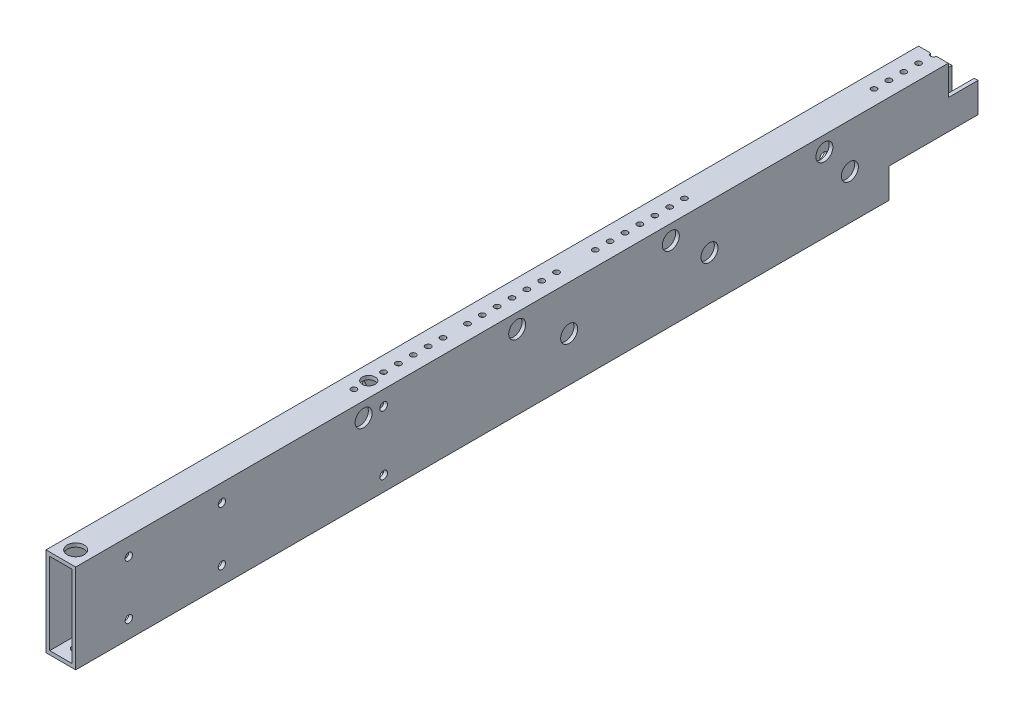
from build123d import *

# Parameters (mm, degrees)
SKETCH1_W                                           = 25.4
SKETCH1_H                                           = 76.2
BOSS_EXTRUDE1_DEPTH                                 = 385.699
SHELL1_T                                            = -3.175
SKETCH2_W                                           = 76.2
SKETCH2_H                                           = 25.4
CUT_EXTRUDE1_DEPTH                                  = 26.4
SKETCH3_W                                           = 25.4
SKETCH3_H                                           = 25.4
CUT_EXTRUDE2_DEPTH                                  = 26.4
SKETCH4_R                                           = 2.38125
CUT_EXTRUDE3_DEPTH                                  = 77.2
CUT_EXTRUDE4_REACH                                  = 78.2
SKETCH5_R                                           = 2.38125
CUT_EXTRUDE5_REACH                                  = 78.2
SKETCH6_R                                           = 2.38125
CBORE_FOR_M6_HEX_HEAD_BOLT1_D                       = 6.3
CBORE_FOR_M6_HEX_HEAD_BOLT1_CBORE_D                 = 14.547
CBORE_FOR_M6_HEX_HEAD_BOLT1_CBORE_DEPTH             = 4
CBORE_FOR_M6_HEX_HEAD_CAP_SCREW1_D                  = 6.6
CBORE_FOR_M6_HEX_HEAD_CAP_SCREW1_CBORE_D            = 14.55
CBORE_FOR_M6_HEX_HEAD_CAP_SCREW1_CBORE_DEPTH        = 4.15
CBORE_FOR_M6_HEX_HEAD_CAP_SCREW2_D                  = 6.6
CBORE_FOR_M6_HEX_HEAD_CAP_SCREW2_CBORE_D            = 14.55
CBORE_FOR_M6_HEX_HEAD_CAP_SCREW2_CBORE_DEPTH        = 4.15
CBORE_FOR_M6_HEX_HEAD_CAP_SCREW3_D                  = 6.6
CBORE_FOR_M6_HEX_HEAD_CAP_SCREW3_CBORE_D            = 14.55
CBORE_FOR_M6_HEX_HEAD_CAP_SCREW3_CBORE_DEPTH        = 4.15
CBORE_FOR_M6_HEX_HEAD_BOLT2_D                       = 6.3
CBORE_FOR_M6_HEX_HEAD_BOLT2_CBORE_D                 = 14.547
CBORE_FOR_M6_HEX_HEAD_BOLT2_CBORE_DEPTH             = 4
CBORE_FOR_M6_HEX_SOCKET_HEAD_CAP_SCREW1_D           = 6.4
CBORE_FOR_M6_HEX_SOCKET_HEAD_CAP_SCREW1_CBORE_D     = 11
CBORE_FOR_M6_HEX_SOCKET_HEAD_CAP_SCREW1_CBORE_DEPTH = 7


with BuildPart() as part:
    # Sketch1 → Boss-Extrude1 (new body, symmetric)
    with BuildSketch(Plane.XY):
        Rectangle(SKETCH1_W, SKETCH1_H)
    extrude(amount=BOSS_EXTRUDE1_DEPTH, both=True)

    # Shell1
    shell1_openings = [part.faces().sort_by_distance(p)[0] for p in [
        (0, 0, 385.699),
        (0, 0, -385.699),
    ]]
    offset(amount=SHELL1_T, openings=shell1_openings, kind=Kind.INTERSECTION)

    # Sketch2 → Cut-Extrude1 (cut, through all)
    with BuildSketch(Plane(origin=(12.7, 0, 0), x_dir=(0, 0, -1), z_dir=(1, 0, 0))):
        with Locations((347.599, -25.4)):
            Rectangle(SKETCH2_W, SKETCH2_H)
    extrude(amount=-CUT_EXTRUDE1_DEPTH, mode=Mode.SUBTRACT)

    # Sketch3 → Cut-Extrude2 (cut, through all)
    with BuildSketch(Plane(origin=(12.7, 0, 0), x_dir=(0, 0, -1), z_dir=(1, 0, 0))):
        with Locations((372.999, 25.4)):
            Rectangle(SKETCH3_W, SKETCH3_H)
    extrude(amount=-CUT_EXTRUDE2_DEPTH, mode=Mode.SUBTRACT)

    # Sketch4 → Cut-Extrude3 (cut, through all)
    with BuildSketch(Plane(origin=(0, 38.1, 0), x_dir=(1, 0, 0), z_dir=(0, 1, 0))):
        with Locations((0, 147.394483214)):
            Circle(SKETCH4_R)
        with Locations((0, 134.694483214)):
            Circle(SKETCH4_R)
        with Locations((0, 121.994483214)):
            Circle(SKETCH4_R)
        with Locations((0, 109.294483214)):
            Circle(SKETCH4_R)
        with Locations((0, 96.594483214)):
            Circle(SKETCH4_R)
        with Locations((0, 83.894483214)):
            Circle(SKETCH4_R)
        with Locations((0, 71.194483214)):
            Circle(SKETCH4_R)
        with Locations((0, 38.09873)):
            Circle(SKETCH4_R)
        with Locations((0, 25.39873)):
            Circle(SKETCH4_R)
        with Locations((0, 12.69873)):
            Circle(SKETCH4_R)
        with Locations((0, -0.00127)):
            Circle(SKETCH4_R)
        with Locations((0, -12.70127)):
            Circle(SKETCH4_R)
        with Locations((0, -25.40127)):
            Circle(SKETCH4_R)
        with Locations((0, -38.10127)):
            Circle(SKETCH4_R)
        with Locations((0, -58.99324371)):
            Circle(SKETCH4_R)
        with Locations((0, -71.69324371)):
            Circle(SKETCH4_R)
        with Locations((0, -84.39324371)):
            Circle(SKETCH4_R)
        with Locations((0, -97.09324371)):
            Circle(SKETCH4_R)
        with Locations((0, -109.79324371)):
            Circle(SKETCH4_R)
        with Locations((0, -122.49324371)):
            Circle(SKETCH4_R)
        with Locations((0, -135.19324371)):
            Circle(SKETCH4_R)
    extrude(amount=-CUT_EXTRUDE3_DEPTH, mode=Mode.SUBTRACT)

    # Sketch5 → Cut-Extrude4 (cut, up to next)
    with BuildSketch(Plane(origin=(0, 38.1, 0), x_dir=(1, 0, 0), z_dir=(0, 1, 0)), mode=Mode.PRIVATE) as cut_extrude4_sk1:
        with Locations((0, 360.299)):
            Circle(SKETCH5_R)
    cut_extrude4_tool1 = extrude(cut_extrude4_sk1.sketch, amount=-CUT_EXTRUDE4_REACH, mode=Mode.PRIVATE) & part.part
    add(cut_extrude4_tool1.solids().sort_by_distance((0, 38.1, -360.299))[0], mode=Mode.SUBTRACT)
    # Sketch5 → Cut-Extrude4 (cut, up to next)
    with BuildSketch(Plane(origin=(0, 38.1, 0), x_dir=(1, 0, 0), z_dir=(0, 1, 0)), mode=Mode.PRIVATE) as cut_extrude4_sk2:
        with Locations((0, 347.599)):
            Circle(SKETCH5_R)
    cut_extrude4_tool2 = extrude(cut_extrude4_sk2.sketch, amount=-CUT_EXTRUDE4_REACH, mode=Mode.PRIVATE) & part.part
    add(cut_extrude4_tool2.solids().sort_by_distance((0, 38.1, -347.599))[0], mode=Mode.SUBTRACT)
    # Sketch5 → Cut-Extrude4 (cut, up to next)
    with BuildSketch(Plane(origin=(0, 38.1, 0), x_dir=(1, 0, 0), z_dir=(0, 1, 0)), mode=Mode.PRIVATE) as cut_extrude4_sk3:
        with Locations((0, 334.899)):
            Circle(SKETCH5_R)
    cut_extrude4_tool3 = extrude(cut_extrude4_sk3.sketch, amount=-CUT_EXTRUDE4_REACH, mode=Mode.PRIVATE) & part.part
    add(cut_extrude4_tool3.solids().sort_by_distance((0, 38.1, -334.899))[0], mode=Mode.SUBTRACT)
    # Sketch5 → Cut-Extrude4 (cut, up to next)
    with BuildSketch(Plane(origin=(0, 38.1, 0), x_dir=(1, 0, 0), z_dir=(0, 1, 0)), mode=Mode.PRIVATE) as cut_extrude4_sk4:
        with Locations((0, 322.199)):
            Circle(SKETCH5_R)
    cut_extrude4_tool4 = extrude(cut_extrude4_sk4.sketch, amount=-CUT_EXTRUDE4_REACH, mode=Mode.PRIVATE) & part.part
    add(cut_extrude4_tool4.solids().sort_by_distance((0, 38.1, -322.199))[0], mode=Mode.SUBTRACT)
    # Sketch5 → Cut-Extrude4 (cut, up to next)
    with BuildSketch(Plane(origin=(0, 38.1, 0), x_dir=(1, 0, 0), z_dir=(0, 1, 0)), mode=Mode.PRIVATE) as cut_extrude4_sk5:
        with Locations((0, 309.499)):
            Circle(SKETCH5_R)
    cut_extrude4_tool5 = extrude(cut_extrude4_sk5.sketch, amount=-CUT_EXTRUDE4_REACH, mode=Mode.PRIVATE) & part.part
    add(cut_extrude4_tool5.solids().sort_by_distance((0, 38.1, -309.499))[0], mode=Mode.SUBTRACT)

    # Sketch6 → Cut-Extrude5 (cut, up to next)
    with BuildSketch(Plane.XZ.offset(38.1), mode=Mode.PRIVATE) as cut_extrude5_sk1:
        with Locations((0, -309.499)):
            Circle(SKETCH6_R)
    cut_extrude5_tool1 = extrude(cut_extrude5_sk1.sketch, amount=-CUT_EXTRUDE5_REACH, mode=Mode.PRIVATE) & part.part
    add(cut_extrude5_tool1.solids().sort_by_distance((0, -38.1, -309.499))[0], mode=Mode.SUBTRACT)
    # Sketch6 → Cut-Extrude5 (cut, up to next)
    with BuildSketch(Plane.XZ.offset(38.1), mode=Mode.PRIVATE) as cut_extrude5_sk2:
        with Locations((0, -296.799)):
            Circle(SKETCH6_R)
    cut_extrude5_tool2 = extrude(cut_extrude5_sk2.sketch, amount=-CUT_EXTRUDE5_REACH, mode=Mode.PRIVATE) & part.part
    add(cut_extrude5_tool2.solids().sort_by_distance((0, -38.1, -296.799))[0], mode=Mode.SUBTRACT)
    # Sketch6 → Cut-Extrude5 (cut, up to next)
    with BuildSketch(Plane.XZ.offset(38.1), mode=Mode.PRIVATE) as cut_extrude5_sk3:
        with Locations((0, -284.099)):
            Circle(SKETCH6_R)
    cut_extrude5_tool3 = extrude(cut_extrude5_sk3.sketch, amount=-CUT_EXTRUDE5_REACH, mode=Mode.PRIVATE) & part.part
    add(cut_extrude5_tool3.solids().sort_by_distance((0, -38.1, -284.099))[0], mode=Mode.SUBTRACT)
    # Sketch6 → Cut-Extrude5 (cut, up to next)
    with BuildSketch(Plane.XZ.offset(38.1), mode=Mode.PRIVATE) as cut_extrude5_sk4:
        with Locations((0, -258.699)):
            Circle(SKETCH6_R)
    cut_extrude5_tool4 = extrude(cut_extrude5_sk4.sketch, amount=-CUT_EXTRUDE5_REACH, mode=Mode.PRIVATE) & part.part
    add(cut_extrude5_tool4.solids().sort_by_distance((0, -38.1, -258.699))[0], mode=Mode.SUBTRACT)
    # Sketch6 → Cut-Extrude5 (cut, up to next)
    with BuildSketch(Plane.XZ.offset(38.1), mode=Mode.PRIVATE) as cut_extrude5_sk5:
        with Locations((0, -271.399)):
            Circle(SKETCH6_R)
    cut_extrude5_tool5 = extrude(cut_extrude5_sk5.sketch, amount=-CUT_EXTRUDE5_REACH, mode=Mode.PRIVATE) & part.part
    add(cut_extrude5_tool5.solids().sort_by_distance((0, -38.1, -271.399))[0], mode=Mode.SUBTRACT)

    # CBORE for M6 Hex Head Bolt1 (through all)
    with Locations(Plane.ZY.offset(12.7)):
        with Locations((260.7244, 23.1254), (260.7244, -23.1), (340.3244, 23.1254), (340.3244, -23.1)):
            CounterBoreHole(CBORE_FOR_M6_HEX_HEAD_BOLT1_D / 2, CBORE_FOR_M6_HEX_HEAD_BOLT1_CBORE_D / 2, CBORE_FOR_M6_HEX_HEAD_BOLT1_CBORE_DEPTH)

    # CBORE for M6 Hex Head Cap Screw1 (through all)
    with Locations(Plane.ZY.offset(12.7)):
        with Locations((122.46784244, 25.4), (122.46784244, -25.4)):
            CounterBoreHole(CBORE_FOR_M6_HEX_HEAD_CAP_SCREW1_D / 2, CBORE_FOR_M6_HEX_HEAD_CAP_SCREW1_CBORE_D / 2, CBORE_FOR_M6_HEX_HEAD_CAP_SCREW1_CBORE_DEPTH)

    # CBORE for M6 Hex Head Cap Screw2 (through all)
    with Locations(Plane(origin=(0, 38.1, 0), x_dir=(1, 0, 0), z_dir=(0, 1, 0))):
        with Locations((0, -372.999)):
            CounterBoreHole(CBORE_FOR_M6_HEX_HEAD_CAP_SCREW2_D / 2, CBORE_FOR_M6_HEX_HEAD_CAP_SCREW2_CBORE_D / 2, CBORE_FOR_M6_HEX_HEAD_CAP_SCREW2_CBORE_DEPTH)

    # CBORE for M6 Hex Head Cap Screw3 (through all)
    with Locations(Plane(origin=(12.7, 0, 0), x_dir=(0, 0, -1), z_dir=(1, 0, 0))):
        with Locations((36.144871949, 0), (156.144871949, 0), (276.144871949, 0)):
            CounterBoreHole(CBORE_FOR_M6_HEX_HEAD_CAP_SCREW3_D / 2, CBORE_FOR_M6_HEX_HEAD_CAP_SCREW3_CBORE_D / 2, CBORE_FOR_M6_HEX_HEAD_CAP_SCREW3_CBORE_DEPTH)

    # CBORE for M6 Hex Head Bolt2 (through all)
    with Locations(Plane(origin=(12.7, 0, 0), x_dir=(0, 0, -1), z_dir=(1, 0, 0))):
        with Locations((254.381, 25.4), (123.063, 25.4), (-8.255, 25.4), (-139.573, 25.4)):
            CounterBoreHole(CBORE_FOR_M6_HEX_HEAD_BOLT2_D / 2, CBORE_FOR_M6_HEX_HEAD_BOLT2_CBORE_D / 2, CBORE_FOR_M6_HEX_HEAD_BOLT2_CBORE_DEPTH)

    # CBORE for M6 Hex Socket Head Cap Screw1 (through all)
    with Locations(Plane(origin=(0, 38.1, 0), x_dir=(1, 0, 0), z_dir=(0, 1, 0))):
        with Locations((0, -122.49324371)):
            CounterBoreHole(CBORE_FOR_M6_HEX_SOCKET_HEAD_CAP_SCREW1_D / 2, CBORE_FOR_M6_HEX_SOCKET_HEAD_CAP_SCREW1_CBORE_D / 2, CBORE_FOR_M6_HEX_SOCKET_HEAD_CAP_SCREW1_CBORE_DEPTH)


solid = part.part
